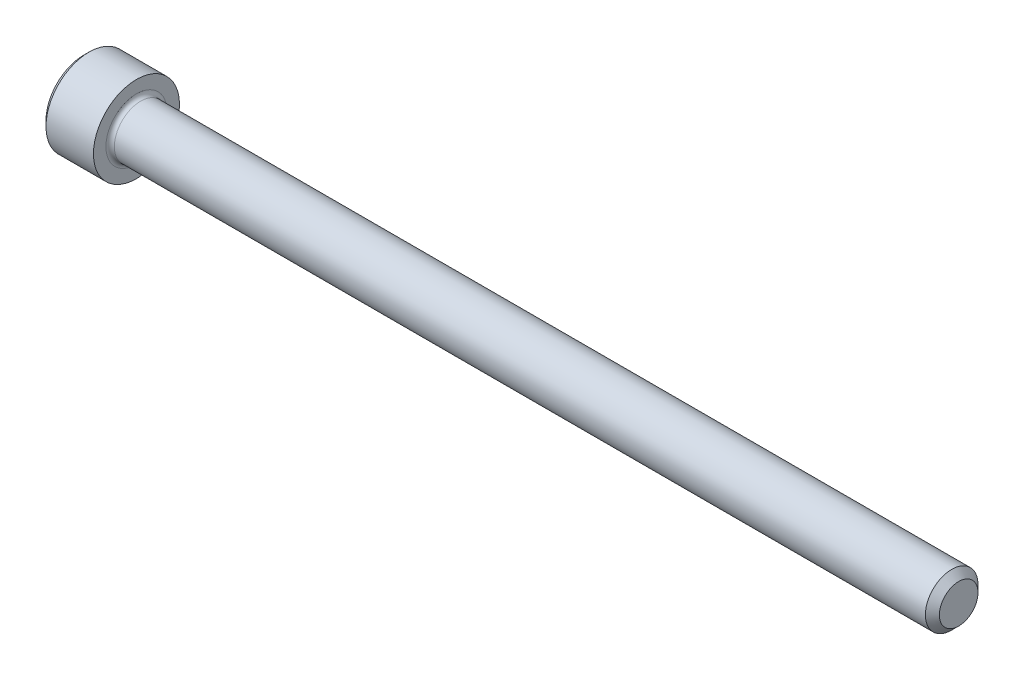
from build123d import *

# Parameters (mm, degrees)
FILLET1_R   = 0.2286
HEX_2_DEPTH = 1.2954


with BuildPart() as part:
    # BodySke → Base-Revolve (revolve)
    with BuildSketch(Plane.XY):
        Polygon((0, 0), (0, 2.0447), (0.2794, 2.3241), (2.8448, 2.3241), (2.8448, 1.4224), (46.91634, 1.4224), (47.2948, 1.04394), (47.2948, 0), align=None)
    revolve(axis=Axis((-31.75, 0, 0), (1, 0, 0)))

    # Fillet1
    fillet1_edges = [part.edges().sort_by_distance(p)[0] for p in [
        (2.8448, -1.4224, 0),
    ]]
    fillet(fillet1_edges, radius=FILLET1_R)

    # Sketch2 → Hex-PreBroach (revolve, cut)
    with BuildSketch(Plane.XY):
        Polygon((0, 1.1938), (1.2954, 1.1938), (1.984640751, 0), (0, 0), align=None)
    revolve(axis=Axis((0, 0, 0), (1, 0, 0)), mode=Mode.SUBTRACT)

    # Sketch3 → Hex 2 (cut)
    with BuildSketch(Plane(origin=(0, 0, 0), x_dir=(0, 0.5, 0.866025404), z_dir=(-1, 0, 0))):
        Polygon((0.689240751, 1.1938), (-0.689240751, 1.1938), (-1.378481503, 0), (-0.689240751, -1.1938), (0.689240751, -1.1938), (1.378481503, 0), align=None)
    extrude(amount=-HEX_2_DEPTH, mode=Mode.SUBTRACT)


solid = part.part
